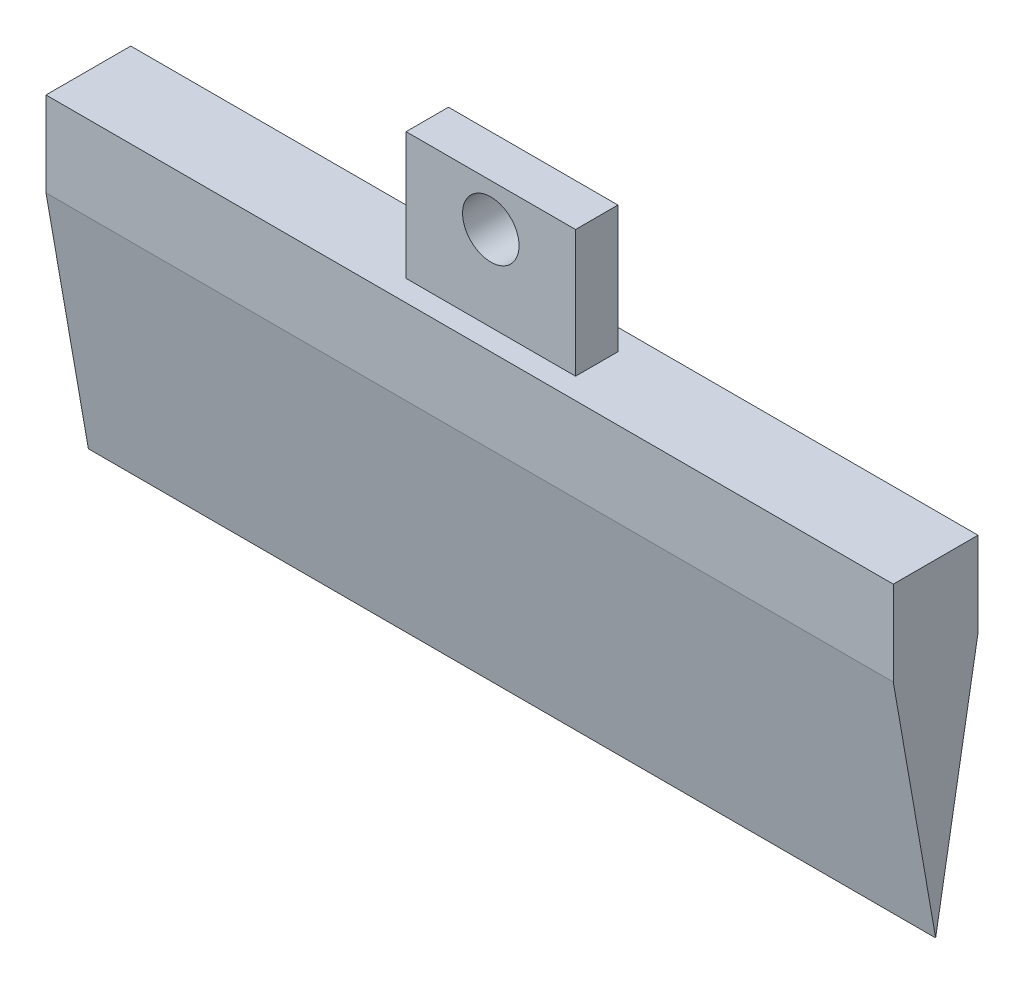
from build123d import *

# Parameters (mm, degrees)
BOSS_EXTRUDE1_DEPTH = 300
SKETCH2_W           = 60
SKETCH2_H           = 45
SKETCH2_R           = 10
BOSS_EXTRUDE2_DEPTH = 7.5


with BuildPart() as part:
    # Sketch1 → Boss-Extrude1 (new body)
    with BuildSketch(Plane(origin=(0, 0, 0), x_dir=(0, 0, -1), z_dir=(1, 0, 0))):
        Polygon((-15, 0), (15, 0), (15, -30), (0, -116), (-15, -30), align=None)
    extrude(amount=-BOSS_EXTRUDE1_DEPTH)

    # Sketch2 → Boss-Extrude2 (add, symmetric)
    with BuildSketch(Plane.XY):
        with Locations((-150, 22.5)):
            Rectangle(SKETCH2_W, SKETCH2_H)
        with Locations((-150, 30)):
            Circle(SKETCH2_R, mode=Mode.SUBTRACT)
    extrude(amount=BOSS_EXTRUDE2_DEPTH, both=True)


solid = part.part
